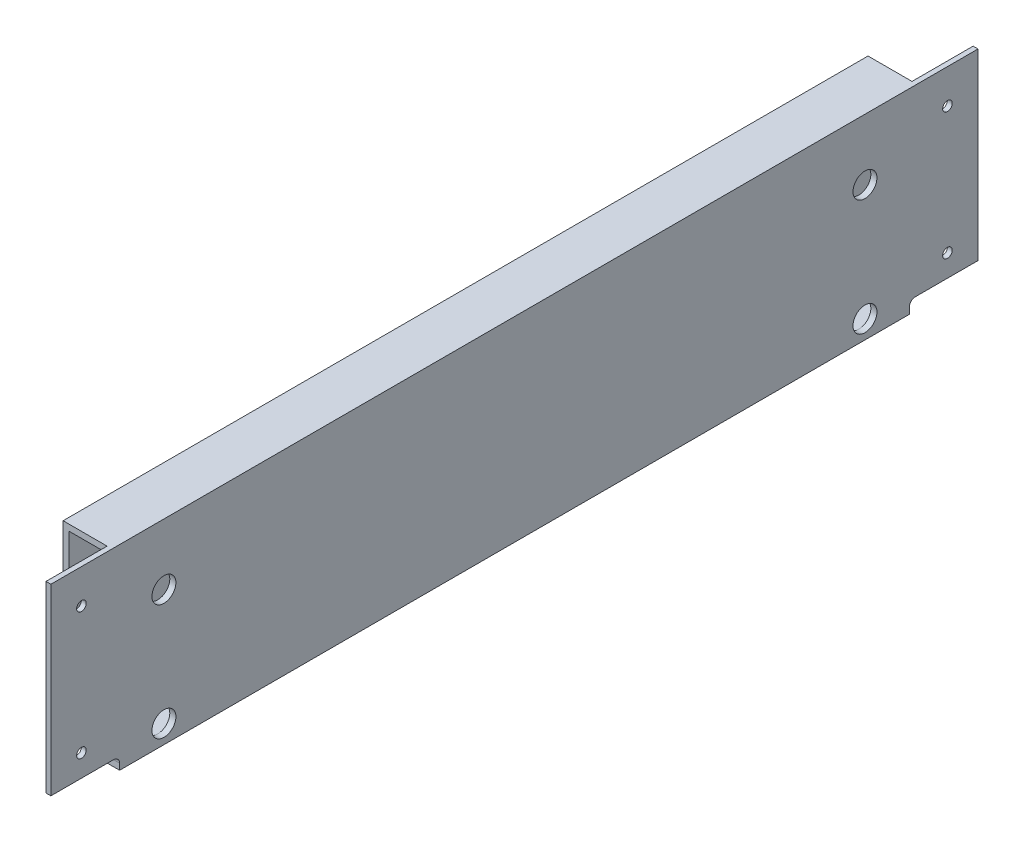
from build123d import *

# Parameters (mm, degrees)
SKETCH1_W                        = 25.4
SKETCH1_H                        = 101.6
SKETCH1_W_2                      = 19.05
SKETCH1_H_2                      = 95.25
EXTRUDE_THIN1_DEPTH              = 240.875
SKETCH2_W                        = 31.75
SKETCH2_H                        = 101.6
CUT_EXTRUDE1_DEPTH               = 22.86
SKETCH3_W                        = 35.71875
SKETCH3_H                        = 6.35
CUT_EXTRUDE2_DEPTH               = 26.4
F_10_CLEARANCE_HOLE1_D           = 4.9784
MIRROR2_COPY_1_D                 = 4.9784
FILLET1_R                        = 3.175
SKETCH7_R                        = 6.223
CUT_EXTRUDE3_DEPTH               = 3.175
F_1_4_CLEARANCE_HOLE1_AT_2_COUNT = 2
F_1_4_CLEARANCE_HOLE1_AT_2_PITCH = 60.325


with BuildPart() as part:
    # Sketch1 → Extrude-Thin1 (new body, symmetric)
    with BuildSketch(Plane.XY):
        Rectangle(SKETCH1_W, SKETCH1_H)
        Rectangle(SKETCH1_W_2, SKETCH1_H_2, mode=Mode.SUBTRACT)
    extrude(amount=EXTRUDE_THIN1_DEPTH, both=True)

    # Sketch2 → Cut-Extrude1 (cut)
    with BuildSketch(Plane.ZY.offset(12.7)):
        with Locations((225, 0)):
            Rectangle(SKETCH2_W, SKETCH2_H)
    cut_extrude1 = extrude(amount=-CUT_EXTRUDE1_DEPTH, mode=Mode.SUBTRACT)

    # Sketch3 → Cut-Extrude2 (cut, through all)
    with BuildSketch(Plane.ZY.offset(12.7)):
        with Locations((223.015625, -47.625)):
            Rectangle(SKETCH3_W, SKETCH3_H)
    cut_extrude2 = extrude(amount=-CUT_EXTRUDE2_DEPTH, mode=Mode.SUBTRACT)

    # #10 Clearance Hole1 (through all)
    with Locations(Plane.ZY.offset(-10.16)):
        with Locations((225, 33.02)):
            f_10_clearance_hole1 = Hole(F_10_CLEARANCE_HOLE1_D / 2)

    # Mirror1: #10 Clearance Hole1 across plane
    add(f_10_clearance_hole1.mirror(Plane.ZX), mode=Mode.SUBTRACT)

    # Mirror2: Cut-Extrude1, Cut-Extrude2, #10 Clearance Hole1 across plane
    add(cut_extrude1.mirror(Plane.XY), mode=Mode.SUBTRACT)
    add(cut_extrude2.mirror(Plane.XY), mode=Mode.SUBTRACT)
    add(f_10_clearance_hole1.mirror(Plane.XY), mode=Mode.SUBTRACT)

    # Mirror2 copy 1 (through all)
    with Locations(Plane(origin=(10.16, 0, 0), x_dir=(0, 0, -1), z_dir=(-1, 0, 0))):
        with Locations((225, 33.02)):
            Hole(MIRROR2_COPY_1_D / 2)

    # Fillet1
    fillet1_edges = [part.edges().sort_by_distance(p)[0] for p in [
        (11.1125, -44.45, 205.15625),
        (-11.1125, -44.45, 205.15625),
        (-11.1125, -44.45, -205.15625),
        (11.1125, -44.45, -205.15625),
    ]]
    fillet(fillet1_edges, radius=FILLET1_R)

    # Sketch7 → Cut-Extrude3 (cut)
    with BuildSketch(Plane.ZY.offset(-9.525)):
        with Locations(Location((182.1375, -41.275, 0), (0, 0, 270))):  # turned: the seam where the file's is
            Circle(SKETCH7_R)
        with Locations(Location((182.1375, 19.05, 0), (0, 0, 270))):  # turned: the seam where the file's is
            Circle(SKETCH7_R)
    cut_extrude3 = extrude(amount=-CUT_EXTRUDE3_DEPTH, mode=Mode.SUBTRACT)

    # Sketch8 → 1/4 Clearance Hole1 (revolve, cut)
    with BuildSketch(Plane(origin=(-12.7, 19.05, 182.1375), x_dir=(0, 0, 1), z_dir=(0, 1, 0))):
        Polygon((0, 0), (0, 3.175), (3.8989, 3.175), (3.2639, 2.54), (3.2639, 0.635), (3.8989, 0), align=None)
    f_1_4_clearance_hole1 = revolve(axis=Axis((-19.05, 19.05, 182.1375), (1, 0, 0)), mode=Mode.SUBTRACT)

    # 1/4 Clearance Hole1 at 2: 1/4 Clearance Hole1 ×2
    with Locations(*[(0, -i * F_1_4_CLEARANCE_HOLE1_AT_2_PITCH, 0) for i in range(1, F_1_4_CLEARANCE_HOLE1_AT_2_COUNT)]):
        add(f_1_4_clearance_hole1, mode=Mode.SUBTRACT)

    # Mirror3: Cut-Extrude3, 1/4 Clearance Hole1 across plane
    add(cut_extrude3.mirror(Plane.XY), mode=Mode.SUBTRACT)
    add(f_1_4_clearance_hole1.mirror(Plane.XY), mode=Mode.SUBTRACT)

    # Mirror3 copy 1 sketch → Mirror3 copy 1 (revolve, cut)
    with BuildSketch(Plane(origin=(-12.7, -41.275, -182.1375), x_dir=(0, 0, -1), z_dir=(0, 1, 0))):
        Polygon((0, 0), (0, -3.175), (3.8989, -3.175), (3.2639, -2.54), (3.2639, -0.635), (3.8989, 0), align=None)
    revolve(axis=Axis((-19.05, -41.275, -182.1375), (-1, 0, 0)), mode=Mode.SUBTRACT)


solid = part.part
